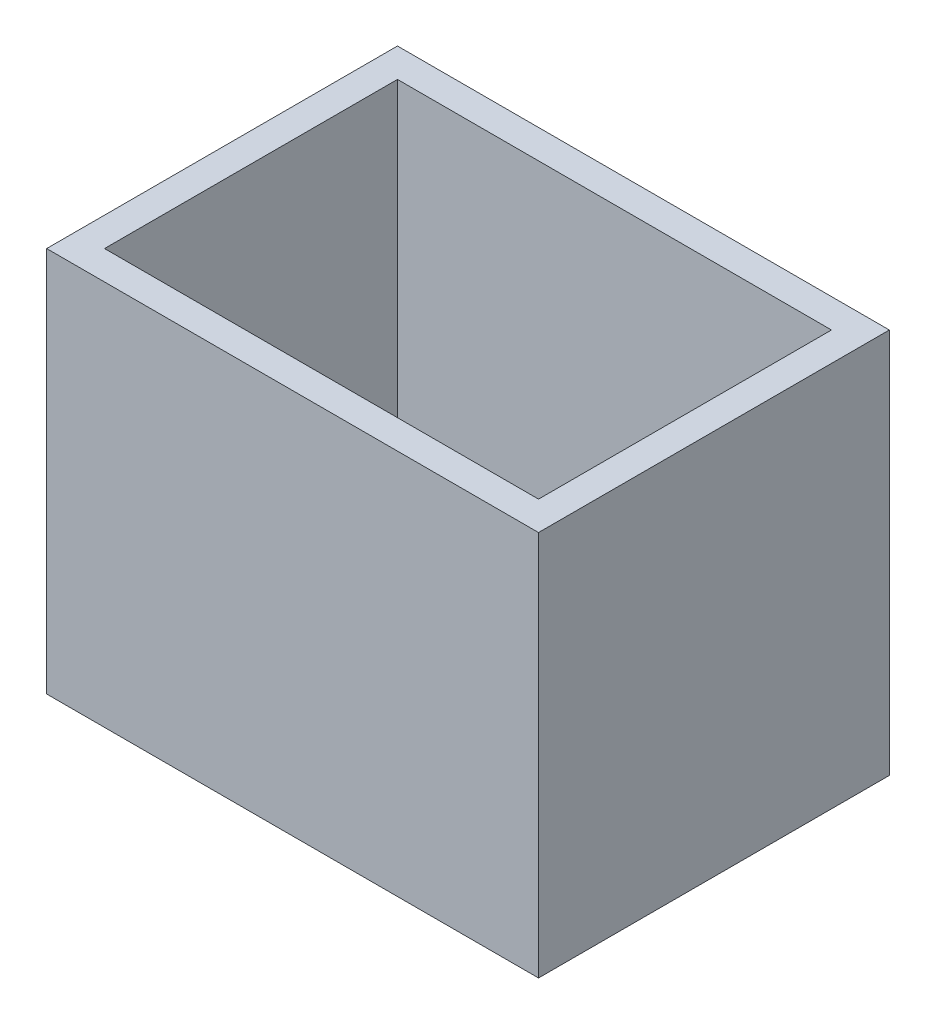
from build123d import *

# Parameters (mm, degrees)
SKETCH_1_W           = 4080
SKETCH_1_H           = 2910
SKETCH_1_W_2         = 3600
SKETCH_1_H_2         = 2430
EXTRUDE_1_DEPTH      = 1200
EXTRUDE_1_DEPTH_BACK = 2000


with BuildPart() as part:
    # 草图1 → 拉伸-薄壁1 (new body, two sides)
    with BuildSketch(Plane(origin=(0, 0, 0), x_dir=(1, 0, 0), z_dir=(0, 1, 0))) as extrude_1_sk:
        with Locations((1800, -1215)):
            Rectangle(SKETCH_1_W, SKETCH_1_H)
        with Locations((1800, -1215)):
            Rectangle(SKETCH_1_W_2, SKETCH_1_H_2, mode=Mode.SUBTRACT)
    extrude(amount=EXTRUDE_1_DEPTH)
    extrude(extrude_1_sk.sketch, amount=-EXTRUDE_1_DEPTH_BACK)


solid = part.part
